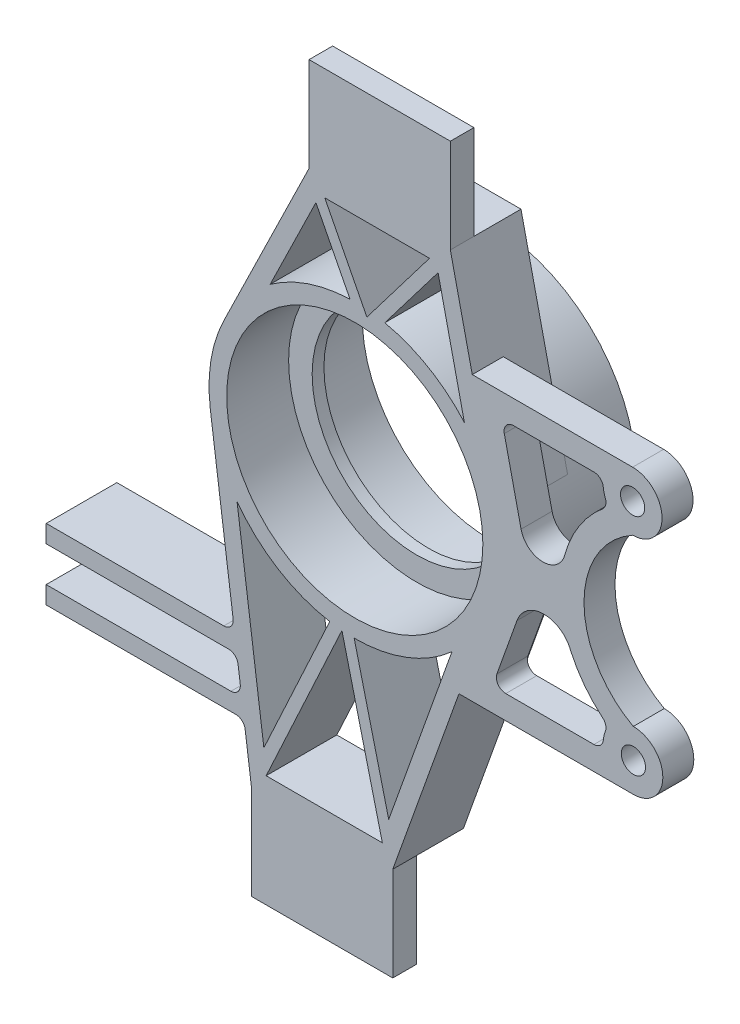
from build123d import *

# Parameters (mm, degrees)
SKETCH1_R                 = 34.544
SKETCH1_W                 = 38.1
SKETCH1_H                 = 25.4
BOSS_EXTRUDE1_DEPTH       = 6.35
BOSS_EXTRUDE1_DEPTH_BACK  = 12.7
CUT_EXTRUDE1_START        = -12.7
SKETCH2_W                 = 38.1
SKETCH2_H                 = 25.4
CUT_EXTRUDE1_DEPTH        = 12.7
SKETCH3_R                 = 39.3065
SKETCH3_R_2               = 34.544
BOSS_EXTRUDE3_DEPTH       = 17.526
SKETCH4_R                 = 34.544
SKETCH4_R_2               = 28.194
BOSS_EXTRUDE4_DEPTH       = 1.5875
BOSS_EXTRUDE10_DEPTH      = 6.35
BOSS_EXTRUDE10_DEPTH_BACK = 2.00152
F_5_16_18_TAPPED_HOLE6_D  = 6.5278
FILLET5_R                 = 2.54
FILLET6_R                 = 2.54
BOSS_EXTRUDE9_DEPTH       = 12.7
BOSS_EXTRUDE9_DEPTH_BACK  = 6.35
FILLET4_R                 = 2.54


with BuildPart() as part:
    # Sketch1 → Boss-Extrude1 (new body, two sides)
    with BuildSketch(Plane.XY) as boss_extrude1_sk:
        with BuildLine():
            Line((-1564.55033403, 132.369836169), (-1537.788605326, 207.210066144))
            ThreePointArc((-1537.788605326, 207.210066144), (-1535.565917531, 218.059885236), (-1536.458056316, 229.099042982))
            Line((-1536.458056316, 229.099042982), (-1549.023662845, 284.769836169))
            Line((-1549.023662845, 284.769836169), (-1587.123662845, 284.769836169))
            Line((-1587.123662845, 284.769836169), (-1610.117979725, 237.697060793))
            ThreePointArc((-1610.117979725, 237.697060793), (-1613.600930979, 226.72878162), (-1613.757951397, 215.221851446))
            Line((-1613.757951397, 215.221851446), (-1602.65033403, 132.369836169))
            Line((-1602.65033403, 132.369836169), (-1564.55033403, 132.369836169))
        make_face()
        with Locations((-1574.8, 220.444778325)):
            Circle(SKETCH1_R, mode=Mode.SUBTRACT)
        with BuildLine():
            Line((-1565.649571077, 143.440187232), (-1574.961325855, 181.138609391))
            ThreePointArc((-1574.961325855, 181.138609391), (-1560.844896551, 183.698948221), (-1548.587601226, 191.154658954))
            Line((-1548.587601226, 191.154658954), (-1565.649571077, 143.440187232))
        make_face(mode=Mode.SUBTRACT)
        with BuildLine():
            Line((-1599.316994088, 143.347801615), (-1606.545707049, 197.266965093))
            ThreePointArc((-1606.545707049, 197.266965093), (-1595.557832884, 187.066442294), (-1581.549876664, 181.722173721))
            Line((-1581.549876664, 181.722173721), (-1599.316994088, 143.347801615))
        make_face(mode=Mode.SUBTRACT)
        Polygon((-1582.899237332, 280.007336169), (-1554.644379273, 280.007336169), (-1571.531413288, 257.824658876), align=None, mode=Mode.SUBTRACT)
        Polygon((-1567.361913884, 137.132336169), (-1578.262893423, 181.264697727), (-1598.695927423, 137.132336169), align=None, mode=Mode.SUBTRACT)
        with BuildLine():
            Line((-1545.232831462, 246.344266484), (-1552.333167166, 277.801667254))
            Line((-1552.333167166, 277.801667254), (-1566.714355054, 258.910650056))
            ThreePointArc((-1566.714355054, 258.910650056), (-1554.952781307, 254.372478695), (-1545.232831462, 246.344266484))
        make_face(mode=Mode.SUBTRACT)
        with BuildLine():
            Line((-1576.07575514, 259.730569536), (-1585.280544841, 277.692395712))
            Line((-1585.280544841, 277.692395712), (-1597.607290416, 252.457720179))
            ThreePointArc((-1597.607290416, 252.457720179), (-1587.378626922, 257.684261229), (-1576.07575514, 259.730569536))
        make_face(mode=Mode.SUBTRACT)
        with Locations((-1568.073662845, 297.469836169)):
            Rectangle(SKETCH1_W, SKETCH1_H)
        with Locations((-1583.60033403, 119.669836169)):
            Rectangle(SKETCH1_W, SKETCH1_H)
    extrude(amount=BOSS_EXTRUDE1_DEPTH)
    extrude(boss_extrude1_sk.sketch, amount=-BOSS_EXTRUDE1_DEPTH_BACK)

    # Sketch2 → Cut-Extrude1 (cut)
    with BuildSketch(Plane(origin=(0, 0, -12.7), x_dir=(-1, 0, 0), z_dir=(0, 0, -1)).offset(CUT_EXTRUDE1_START)):
        with Locations((1568.073662845, 297.469836169)):
            Rectangle(SKETCH2_W, SKETCH2_H)
        with Locations((1583.60033403, 119.669836169)):
            Rectangle(SKETCH2_W, SKETCH2_H)
    extrude(amount=CUT_EXTRUDE1_DEPTH, mode=Mode.SUBTRACT)

    # Sketch3 → Boss-Extrude3 (add)
    with BuildSketch(Plane(origin=(0, 0, -12.7), x_dir=(-1, 0, 0), z_dir=(0, 0, -1))):
        with Locations((1574.8, 220.444778325)):
            Circle(SKETCH3_R)
        with Locations((1574.8, 220.444778325)):
            Circle(SKETCH3_R_2, mode=Mode.SUBTRACT)
    extrude(amount=BOSS_EXTRUDE3_DEPTH)

    # Sketch4 → Boss-Extrude4 (add, symmetric)
    with BuildSketch(Plane(origin=(0, 0, -11.938), x_dir=(-1, 0, 0), z_dir=(0, 0, -1))):
        with Locations((1574.8, 220.444778325)):
            Circle(SKETCH4_R)
        with Locations((1574.8, 220.444778325)):
            Circle(SKETCH4_R_2, mode=Mode.SUBTRACT)
    extrude(amount=BOSS_EXTRUDE4_DEPTH, both=True)

    # Sketch50 → Boss-Extrude10 (add, two sides)
    with BuildSketch(Plane.XY) as boss_extrude10_sk:
        with BuildLine():
            Line((-1541.32707152, 250.670778325), (-1536.458056316, 229.099042982))
            ThreePointArc((-1536.458056316, 229.099042982), (-1535.565917531, 218.059885236), (-1537.788605326, 207.210066144))
            Line((-1537.788605326, 207.210066144), (-1543.86443159, 190.218778325))
            Line((-1543.86443159, 190.218778325), (-1546.702760944, 182.281278325))
            Line((-1546.702760944, 182.281278325), (-1499.66049752, 182.281278325))
            ThreePointArc((-1499.66049752, 182.281278325), (-1491.723009436, 190.232532365), (-1499.688005558, 198.156230659))
            ThreePointArc((-1499.688005558, 198.156230659), (-1512.984254944, 220.398966531), (-1499.842491961, 242.733325991))
            ThreePointArc((-1499.842491961, 242.733325991), (-1491.932511916, 250.684532365), (-1499.87, 258.608278325))
            Line((-1499.87, 258.608278325), (-1543.118666289, 258.608278325))
            Line((-1543.118666289, 258.608278325), (-1541.32707152, 250.670778325))
        make_face()
        with BuildLine():
            Line((-1535.178710458, 252.258278325), (-1507.647129933, 252.258278325))
            ThreePointArc((-1507.647129933, 252.258278325), (-1507.638572597, 249.041917968), (-1506.354439589, 246.09301146))
            ThreePointArc((-1506.354439589, 246.09301146), (-1513.671222734, 238.58285904), (-1518.142792697, 229.099042982))
            ThreePointArc((-1518.142792697, 229.099042982), (-1524.047084498, 224.378892556), (-1529.9513763, 229.099042982))
            Line((-1529.9513763, 229.099042982), (-1535.178710458, 252.258278325))
        make_face(mode=Mode.SUBTRACT)
        with BuildLine():
            Line((-1507.647129933, 188.631278325), (-1537.68832903, 188.631278325))
            Line((-1537.68832903, 188.631278325), (-1531.044836894, 207.210066144))
            ThreePointArc((-1531.044836894, 207.210066144), (-1523.771769284, 212.333403895), (-1516.498701674, 207.210066144))
            ThreePointArc((-1516.498701674, 207.210066144), (-1512.22122179, 200.353921044), (-1506.354439589, 194.79654519))
            ThreePointArc((-1506.354439589, 194.79654519), (-1507.638572597, 191.847638682), (-1507.647129933, 188.631278325))
        make_face(mode=Mode.SUBTRACT)
    extrude(amount=BOSS_EXTRUDE10_DEPTH)
    extrude(boss_extrude10_sk.sketch, amount=-BOSS_EXTRUDE10_DEPTH_BACK)

    # 5_16-18 Tapped Hole6 (through all)
    with Locations(Plane.XY.offset(6.35)):
        with Locations((-1499.87, 250.670778325), (-1499.66049752, 190.218778325)):
            Hole(F_5_16_18_TAPPED_HOLE6_D / 2)

    # Fillet5
    fillet5_edges = [part.edges().sort_by_distance(p)[0] for p in [
        (-1506.354439589, 246.09301146, 2.17424),
        (-1507.647129933, 252.258278325, 2.17424),
        (-1506.354439589, 194.79654519, 2.17424),
        (-1507.647129933, 188.631278325, 2.17424),
    ]]
    fillet(fillet5_edges, radius=FILLET5_R)

    # Fillet6
    fillet6_edges = [part.edges().sort_by_distance(p)[0] for p in [
        (-1535.178710458, 252.258278325, 2.17424),
        (-1537.68832903, 188.631278325, 2.17424),
    ]]
    fillet(fillet6_edges, radius=FILLET6_R)

    # rod connection → Boss-Extrude9 (add, two sides)
    with BuildSketch(Plane(origin=(0, 0, 0), x_dir=(-1, 0, 0), z_dir=(0, 0, -1))) as boss_extrude9_sk:
        Polygon((1647.10033403, 161.645888869), (1606.575249921, 161.645888869), (1607.213738044, 166.408388869), (1658.013738044, 166.408388869), (1658.013738044, 161.645888869), align=None)
        Polygon((1647.10033403, 152.120888869), (1605.298273676, 152.120888869), (1604.659785553, 147.358388869), (1658.013738044, 147.358388869), (1658.013738044, 152.120888869), align=None)
    extrude(amount=BOSS_EXTRUDE9_DEPTH)
    extrude(boss_extrude9_sk.sketch, amount=-BOSS_EXTRUDE9_DEPTH_BACK)

    # Fillet4
    fillet4_edges = [part.edges().sort_by_distance(p)[0] for p in [
        (-1605.298273676, 152.120888869, -3.175),
        (-1604.659785553, 147.358388869, -3.175),
        (-1607.213738044, 166.408388869, -3.175),
        (-1606.575249921, 161.645888869, -3.175),
    ]]
    fillet(fillet4_edges, radius=FILLET4_R)


solid = part.part
